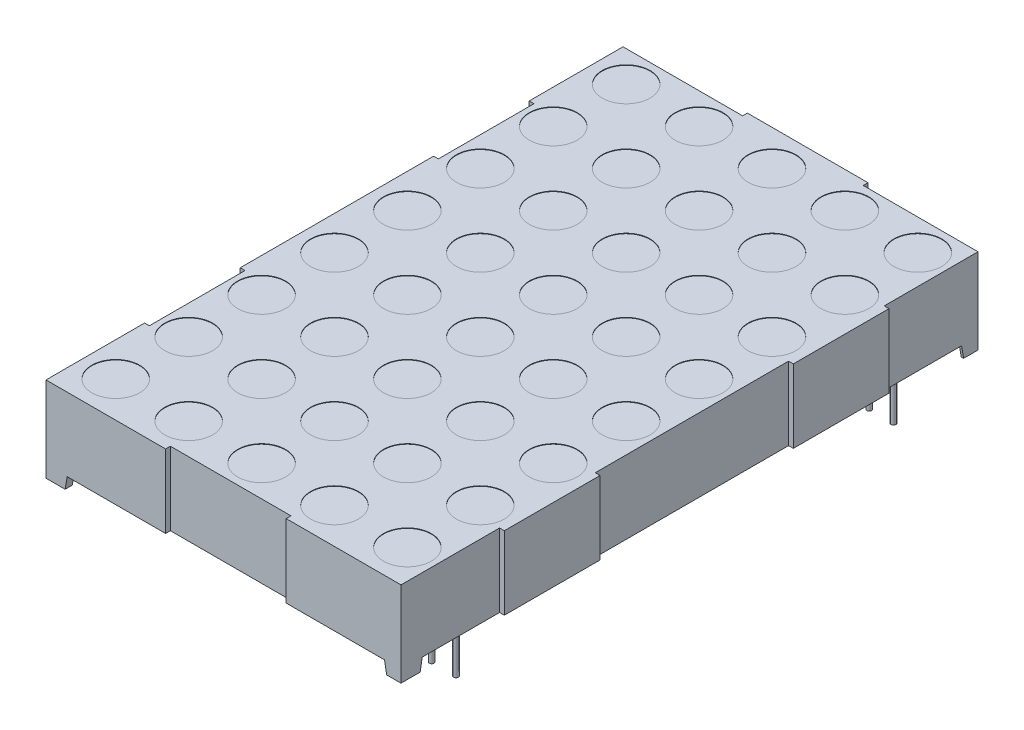
from build123d import *
from build123d.topology import SkipClean

# Parameters (mm, degrees)
EXTRUDE1_DEPTH     = 18.8
CUT_EXTRUDE1_DEPTH = 61.8
SKETCH2_R          = 2.5
CUT_EXTRUDE2_DEPTH = 0.05
SKETCH4_R          = 0.25
EXTRUDE2_DEPTH     = 1.25
SKETCH4_3_R        = 0.25
EXTRUDE3_DEPTH     = 4
SKETCH4_4_W        = 1.470408726
SKETCH4_4_H        = 1.470408726
CUT_EXTRUDE3_DEPTH = 1.25
SKETCH2_4_W        = 0.5
SKETCH2_4_H        = 10
SKETCH2_4_H_2      = 10.3
SKETCH2_4_H_3      = 20.2
SKETCH2_4_W_2      = 12.5
SKETCH2_4_H_4      = 0.5
SKETCH2_4_W_3      = 12
SKETCH2_4_W_4      = 12.6
CUT_EXTRUDE5_DEPTH = 13.9
SKETCH5_W          = 0.025316456
SKETCH5_H          = 0.026582279
CUT_EXTRUDE6_DEPTH = 0.01


with BuildPart() as part:
    # Sketch1 → Extrude1 (new body, symmetric)
    with BuildSketch(Plane(origin=(0, 0, 0), x_dir=(0, 0, -1), z_dir=(1, 0, 0))):
        Polygon((30.4, 4.45), (-30.4, 4.45), (21.860674157, -3.2), (28.179591274, -3.2), (28.347010236, -4.149480117), (30.4, -4.45), align=None)
        Polygon((21.860674157, -3.2), (-30.4, 4.45), (-30.4, -4.45), (-28.4, -4.45), (-28.179591274, -3.2), align=None)
        Polygon((30.4, -4.45), (28.347010236, -4.149480117), (28.4, -4.45), align=None)
    extrude(amount=EXTRUDE1_DEPTH, both=True)

    # Sketch3 → Cut-Extrude1 (cut, through all)
    with BuildSketch(Plane.XY.offset(30.4)):
        Polygon((-16.579591274, -3.2), (-16.8, -4.45), (16.8, -4.45), (16.579591274, -3.2), align=None)
    extrude(amount=-CUT_EXTRUDE1_DEPTH, mode=Mode.SUBTRACT)

    # Sketch2 → Cut-Extrude2 (cut)
    with BuildSketch(Plane(origin=(0, 4.45, 0), x_dir=(-1, 0, 0), z_dir=(0, 1, 0))):
        with Locations(Location((15.24, -19.05, 0), (0, 0, 90))):  # turned: the seam where the file's is
            Circle(SKETCH2_R)
        with Locations(Location((7.62, -19.05, 0), (0, 0, 90))):  # turned: the seam where the file's is
            Circle(SKETCH2_R)
        with Locations(Location((0, -19.05, 0), (0, 0, 90))):  # turned: the seam where the file's is
            Circle(SKETCH2_R)
        with Locations(Location((-7.62, -19.05, 0), (0, 0, 90))):  # turned: the seam where the file's is
            Circle(SKETCH2_R)
        with Locations(Location((-15.24, -19.05, 0), (0, 0, 90))):  # turned: the seam where the file's is
            Circle(SKETCH2_R)
        with Locations(Location((-15.24, -11.43, 0), (0, 0, 90))):  # turned: the seam where the file's is
            Circle(SKETCH2_R)
        with Locations(Location((-7.62, -11.43, 0), (0, 0, 90))):  # turned: the seam where the file's is
            Circle(SKETCH2_R)
        with Locations(Location((0, -11.43, 0), (0, 0, 90))):  # turned: the seam where the file's is
            Circle(SKETCH2_R)
        with Locations(Location((7.62, -11.43, 0), (0, 0, 90))):  # turned: the seam where the file's is
            Circle(SKETCH2_R)
        with Locations(Location((15.24, -11.43, 0), (0, 0, 90))):  # turned: the seam where the file's is
            Circle(SKETCH2_R)
        with Locations(Location((15.24, -3.81, 0), (0, 0, 90))):  # turned: the seam where the file's is
            Circle(SKETCH2_R)
        with Locations(Location((7.62, -3.81, 0), (0, 0, 90))):  # turned: the seam where the file's is
            Circle(SKETCH2_R)
        with Locations(Location((0, -3.81, 0), (0, 0, 90))):  # turned: the seam where the file's is
            Circle(SKETCH2_R)
        with Locations(Location((-7.62, -3.81, 0), (0, 0, 90))):  # turned: the seam where the file's is
            Circle(SKETCH2_R)
        with Locations(Location((-15.24, -3.81, 0), (0, 0, 90))):  # turned: the seam where the file's is
            Circle(SKETCH2_R)
        with Locations(Location((-15.24, 3.81, 0), (0, 0, 90))):  # turned: the seam where the file's is
            Circle(SKETCH2_R)
        with Locations(Location((-7.62, 3.81, 0), (0, 0, 90))):  # turned: the seam where the file's is
            Circle(SKETCH2_R)
        with Locations(Location((0, 3.81, 0), (0, 0, 90))):  # turned: the seam where the file's is
            Circle(SKETCH2_R)
        with Locations(Location((7.62, 3.81, 0), (0, 0, 90))):  # turned: the seam where the file's is
            Circle(SKETCH2_R)
        with Locations(Location((15.24, 3.81, 0), (0, 0, 90))):  # turned: the seam where the file's is
            Circle(SKETCH2_R)
        with Locations(Location((15.24, 11.43, 0), (0, 0, 90))):  # turned: the seam where the file's is
            Circle(SKETCH2_R)
        with Locations(Location((7.62, 11.43, 0), (0, 0, 90))):  # turned: the seam where the file's is
            Circle(SKETCH2_R)
        with Locations(Location((0, 11.43, 0), (0, 0, 90))):  # turned: the seam where the file's is
            Circle(SKETCH2_R)
        with Locations(Location((-7.62, 11.43, 0), (0, 0, 90))):  # turned: the seam where the file's is
            Circle(SKETCH2_R)
        with Locations(Location((-15.24, 11.43, 0), (0, 0, 90))):  # turned: the seam where the file's is
            Circle(SKETCH2_R)
        with Locations(Location((-15.24, 19.05, 0), (0, 0, 90))):  # turned: the seam where the file's is
            Circle(SKETCH2_R)
        with Locations(Location((-7.62, 19.05, 0), (0, 0, 90))):  # turned: the seam where the file's is
            Circle(SKETCH2_R)
        with Locations(Location((0, 19.05, 0), (0, 0, 90))):  # turned: the seam where the file's is
            Circle(SKETCH2_R)
        with Locations(Location((7.62, 19.05, 0), (0, 0, 90))):  # turned: the seam where the file's is
            Circle(SKETCH2_R)
        with Locations(Location((15.24, 19.05, 0), (0, 0, 90))):  # turned: the seam where the file's is
            Circle(SKETCH2_R)
        with Locations(Location((15.24, 26.67, 0), (0, 0, 90))):  # turned: the seam where the file's is
            Circle(SKETCH2_R)
        with Locations(Location((7.62, 26.67, 0), (0, 0, 90))):  # turned: the seam where the file's is
            Circle(SKETCH2_R)
        with Locations(Location((0, 26.67, 0), (0, 0, 90))):  # turned: the seam where the file's is
            Circle(SKETCH2_R)
        with Locations(Location((-7.62, 26.67, 0), (0, 0, 90))):  # turned: the seam where the file's is
            Circle(SKETCH2_R)
        with Locations(Location((-15.24, 26.67, 0), (0, 0, 90))):  # turned: the seam where the file's is
            Circle(SKETCH2_R)
        with Locations(Location((15.24, -26.67, 0), (0, 0, 90))):  # turned: the seam where the file's is
            Circle(SKETCH2_R)
        with Locations(Location((7.62, -26.67, 0), (0, 0, 90))):  # turned: the seam where the file's is
            Circle(SKETCH2_R)
        with Locations(Location((0, -26.67, 0), (0, 0, 90))):  # turned: the seam where the file's is
            Circle(SKETCH2_R)
        with Locations(Location((-7.62, -26.67, 0), (0, 0, 90))):  # turned: the seam where the file's is
            Circle(SKETCH2_R)
        with Locations(Location((-15.24, -26.67, 0), (0, 0, 90))):  # turned: the seam where the file's is
            Circle(SKETCH2_R)
    extrude(amount=-CUT_EXTRUDE2_DEPTH, mode=Mode.SUBTRACT)

    # Sketch4 → Extrude2 (add)
    with BuildSketch(Plane.XZ.offset(4.45)):
        with Locations((-6.35, 22.86)):
            Circle(SKETCH4_R)
        with Locations(Location((-3.81, 22.86, 0), (0, 0, 270))):  # turned: the seam where the file's is
            Circle(SKETCH4_R)
        with Locations(Location((-1.27, 22.86, 0), (0, 0, 270))):  # turned: the seam where the file's is
            Circle(SKETCH4_R)
        with Locations(Location((8.89, 22.86, 0), (0, 0, 270))):  # turned: the seam where the file's is
            Circle(SKETCH4_R)
        with Locations((1.27, 22.86)):
            Circle(SKETCH4_R)
        with Locations(Location((3.81, 22.86, 0), (0, 0, 270))):  # turned: the seam where the file's is
            Circle(SKETCH4_R)
        with Locations(Location((6.35, 22.86, 0), (0, 0, 270))):  # turned: the seam where the file's is
            Circle(SKETCH4_R)
        with Locations(Location((-1.27, -22.86, 0), (0, 0, 180))):  # turned: the seam where the file's is
            Circle(SKETCH4_R)
        with Locations(Location((16.51, -22.86, 0), (0, 0, 180))):  # turned: the seam where the file's is
            Circle(SKETCH4_R)
        with Locations(Location((13.97, -22.86, 0), (0, 0, 180))):  # turned: the seam where the file's is
            Circle(SKETCH4_R)
        with Locations(Location((-16.51, -22.86, 0), (0, 0, 180))):  # turned: the seam where the file's is
            Circle(SKETCH4_R)
        with Locations(Location((-13.97, -22.86, 0), (0, 0, 180))):  # turned: the seam where the file's is
            Circle(SKETCH4_R)
        with Locations(Location((-11.43, -22.86, 0), (0, 0, 180))):  # turned: the seam where the file's is
            Circle(SKETCH4_R)
        with Locations(Location((-8.89, -22.86, 0), (0, 0, 180))):  # turned: the seam where the file's is
            Circle(SKETCH4_R)
        with Locations((11.43, 22.86)):
            Circle(SKETCH4_R)
        with Locations((-8.89, 22.86)):
            Circle(SKETCH4_R)
        with Locations(Location((11.43, -22.86, 0), (0, 0, 180))):  # turned: the seam where the file's is
            Circle(SKETCH4_R)
        with Locations(Location((6.35, -22.86, 0), (0, 0, 180))):  # turned: the seam where the file's is
            Circle(SKETCH4_R)
        with Locations((-11.43, 22.86)):
            Circle(SKETCH4_R)
        with Locations((-13.97, 22.86)):
            Circle(SKETCH4_R)
        with Locations((-16.51, 22.86)):
            Circle(SKETCH4_R)
        with Locations((13.97, 22.86)):
            Circle(SKETCH4_R)
        with Locations((16.51, 22.86)):
            Circle(SKETCH4_R)
        with Locations(Location((3.81, -22.86, 0), (0, 0, 180))):  # turned: the seam where the file's is
            Circle(SKETCH4_R)
        with Locations(Location((1.27, -22.86, 0), (0, 0, 180))):  # turned: the seam where the file's is
            Circle(SKETCH4_R)
        with Locations(Location((8.89, -22.86, 0), (0, 0, 180))):  # turned: the seam where the file's is
            Circle(SKETCH4_R)
        with Locations(Location((-3.81, -22.86, 0), (0, 0, 180))):  # turned: the seam where the file's is
            Circle(SKETCH4_R)
        with Locations(Location((-6.35, -22.86, 0), (0, 0, 180))):  # turned: the seam where the file's is
            Circle(SKETCH4_R)
    extrude(amount=-EXTRUDE2_DEPTH)

    # Sketch4_3 → Extrude3 (add)
    with SkipClean():  # keep this step's faces unmerged: merging them makes the solid invalid here
        with BuildSketch(Plane.XZ.offset(4.45)):
            with Locations((-6.35, 22.86)):
                Circle(SKETCH4_3_R)
            with Locations((-3.81, 22.86)):
                Circle(SKETCH4_3_R)
            with Locations((-1.27, 22.86)):
                Circle(SKETCH4_3_R)
            with Locations((8.89, 22.86)):
                Circle(SKETCH4_3_R)
            with Locations((1.27, 22.86)):
                Circle(SKETCH4_3_R)
            with Locations((3.81, 22.86)):
                Circle(SKETCH4_3_R)
            with Locations(Location((6.35, 22.86, 0), (0, 0, 270))):  # turned: the seam where the file's is
                Circle(SKETCH4_3_R)
            with Locations(Location((-1.27, -22.86, 0), (0, 0, 180))):  # turned: the seam where the file's is
                Circle(SKETCH4_3_R)
            with Locations(Location((16.51, -22.86, 0), (0, 0, 180))):  # turned: the seam where the file's is
                Circle(SKETCH4_3_R)
            with Locations(Location((13.97, -22.86, 0), (0, 0, 180))):  # turned: the seam where the file's is
                Circle(SKETCH4_3_R)
            with Locations(Location((-16.51, -22.86, 0), (0, 0, 180))):  # turned: the seam where the file's is
                Circle(SKETCH4_3_R)
            with Locations(Location((-13.97, -22.86, 0), (0, 0, 180))):  # turned: the seam where the file's is
                Circle(SKETCH4_3_R)
            with Locations(Location((-11.43, -22.86, 0), (0, 0, 180))):  # turned: the seam where the file's is
                Circle(SKETCH4_3_R)
            with Locations(Location((-8.89, -22.86, 0), (0, 0, 180))):  # turned: the seam where the file's is
                Circle(SKETCH4_3_R)
            with Locations((11.43, 22.86)):
                Circle(SKETCH4_3_R)
            with Locations((-8.89, 22.86)):
                Circle(SKETCH4_3_R)
            with Locations(Location((11.43, -22.86, 0), (0, 0, 180))):  # turned: the seam where the file's is
                Circle(SKETCH4_3_R)
            with Locations(Location((6.35, -22.86, 0), (0, 0, 180))):  # turned: the seam where the file's is
                Circle(SKETCH4_3_R)
            with Locations((-11.43, 22.86)):
                Circle(SKETCH4_3_R)
            with Locations((-13.97, 22.86)):
                Circle(SKETCH4_3_R)
            with Locations((-16.51, 22.86)):
                Circle(SKETCH4_3_R)
            with Locations((13.97, 22.86)):
                Circle(SKETCH4_3_R)
            with Locations((16.51, 22.86)):
                Circle(SKETCH4_3_R)
            with Locations(Location((3.81, -22.86, 0), (0, 0, 180))):  # turned: the seam where the file's is
                Circle(SKETCH4_3_R)
            with Locations(Location((1.27, -22.86, 0), (0, 0, 180))):  # turned: the seam where the file's is
                Circle(SKETCH4_3_R)
            with Locations(Location((8.89, -22.86, 0), (0, 0, 180))):  # turned: the seam where the file's is
                Circle(SKETCH4_3_R)
            with Locations(Location((-3.81, -22.86, 0), (0, 0, 180))):  # turned: the seam where the file's is
                Circle(SKETCH4_3_R)
            with Locations(Location((-6.35, -22.86, 0), (0, 0, 180))):  # turned: the seam where the file's is
                Circle(SKETCH4_3_R)
        extrude(amount=EXTRUDE3_DEPTH)

    # Sketch4_4 → Cut-Extrude3 (cut)
    with SkipClean():  # keep this step's faces unmerged: merging them makes the solid invalid here
        with BuildSketch(Plane.XZ.offset(4.45)):
            with Locations((-17.314795637, 28.914795637)):
                Rectangle(SKETCH4_4_W, SKETCH4_4_H)
            with Locations((17.314795637, 28.914795637)):
                Rectangle(SKETCH4_4_W, SKETCH4_4_H)
            with Locations((17.314795637, -28.914795637)):
                Rectangle(SKETCH4_4_W, SKETCH4_4_H)
            with Locations((-17.314795637, -28.914795637)):
                Rectangle(SKETCH4_4_W, SKETCH4_4_H)
        extrude(amount=-CUT_EXTRUDE3_DEPTH, mode=Mode.SUBTRACT)

    # Sketch2_4 → Cut-Extrude5 (cut, through all)
    with SkipClean():  # keep this step's faces unmerged: merging them makes the solid invalid here
        with BuildSketch(Plane(origin=(0, 4.45, 0), x_dir=(-1, 0, 0), z_dir=(0, 1, 0))):
            with Locations((18.55, -15.1)):
                Rectangle(SKETCH2_4_W, SKETCH2_4_H)
            with Locations((18.55, 15.1)):
                Rectangle(SKETCH2_4_W, SKETCH2_4_H)
            with Locations((-18.55, 25.25)):
                Rectangle(SKETCH2_4_W, SKETCH2_4_H_2)
            with Locations((-18.55, 0)):
                Rectangle(SKETCH2_4_W, SKETCH2_4_H_3)
            Polygon((-18.8, -30.4), (-18.3, -30.4), (-18.3, -29.9), (-18.3, -20.1), (-18.8, -20.1), align=None)
            with Locations((12.55, -30.15)):
                Rectangle(SKETCH2_4_W_2, SKETCH2_4_H_4)
            with Locations((-12.3, -30.15)):
                Rectangle(SKETCH2_4_W_3, SKETCH2_4_H_4)
            with Locations((0, 30.15)):
                Rectangle(SKETCH2_4_W_4, SKETCH2_4_H_4)
        extrude(amount=-CUT_EXTRUDE5_DEPTH, mode=Mode.SUBTRACT)

    # Sketch5 → Cut-Extrude6 (cut)
    with SkipClean():  # keep this step's faces unmerged: merging them makes the solid invalid here
        with BuildSketch(Plane.XZ.offset(3.2)):
            Polygon((0.649619863, 18.964879029), (0.673077141, 19.039562573), (0.697820021, 19.039562573), (0.71423616, 18.989226339), (0.729762268, 19.039562573), (0.755494071, 19.039562573), (0.778733787, 18.964879029), (0.75355578, 18.964879029), (0.740561318, 19.016362415), (0.724145179, 18.964879029), (0.70264597, 18.964879029), (0.686328723, 19.016362415), (0.673512268, 18.964879029), align=None)
            Polygon((0.515442647, 18.964879029), (0.538899926, 19.039562573), (0.563642806, 19.039562573), (0.580058945, 18.989226339), (0.595585052, 19.039562573), (0.621316856, 19.039562573), (0.644556571, 18.964879029), (0.619378565, 18.964879029), (0.606384103, 19.016362415), (0.589967964, 18.964879029), (0.568468755, 18.964879029), (0.552151508, 19.016362415), (0.539335052, 18.964879029), align=None)
            Polygon((0.381265432, 18.964879029), (0.404722711, 19.039562573), (0.42946559, 19.039562573), (0.44588173, 18.989226339), (0.461407837, 19.039562573), (0.487139641, 19.039562573), (0.510379356, 18.964879029), (0.48520135, 18.964879029), (0.472206888, 19.016362415), (0.455790749, 18.964879029), (0.43429154, 18.964879029), (0.417974293, 19.016362415), (0.405157837, 18.964879029), align=None)
            with Locations((0.353417331, 19.026271433)):
                Rectangle(SKETCH5_W, SKETCH5_H)
            with BuildLine():
                add(Edge.make_bspline(
                    [(0.236961635, 19.008391687), (0.236998163, 19.009613801), (0.237069892, 19.012013625), (0.237679054, 19.015521591), (0.238674578, 19.018844874), (0.240038916, 19.02200759), (0.241852904, 19.024962956), (0.244007918, 19.027781523), (0.246619832, 19.030365485), (0.249556869, 19.032804246), (0.252854796, 19.034986641), (0.256457418, 19.036886779), (0.260327738, 19.038511498), (0.264481758, 19.039843187), (0.268927336, 19.040833955), (0.273645113, 19.041557272), (0.278638461, 19.04203078), (0.282062049, 19.042072721), (0.283816856, 19.042094218)],
                    knots=[0, 0, 0, 0, 0.907421153, 1.781872267, 2.635683434, 3.480115191, 4.332689235, 5.205575272, 6.109500117, 7.055808355, 8.037942167, 9.041423561, 10.07750834, 11.152467461, 12.277657752, 13.45734338, 14.696726425, 16, 16, 16, 16], degree=3))
                add(Edge.make_bspline(
                    [(0.283816856, 19.042094218), (0.285834841, 19.042066954), (0.289743027, 19.04201415), (0.295410595, 19.041628777), (0.300674061, 19.040940827), (0.305571809, 19.039984247), (0.310176109, 19.038780962), (0.314609454, 19.037490318), (0.318890746, 19.036025737), (0.321663838, 19.034925601), (0.323037584, 19.034380611)],
                    knots=[0, 0, 0, 0, 1.203182053, 2.33017619, 3.384818652, 4.366208123, 5.30340534, 6.221361684, 7.118890722, 8, 8, 8, 8], degree=3))
                Line((0.323037584, 19.034380611), (0.323037584, 19.010448649))
                Line((0.323037584, 19.010448649), (0.320189483, 19.010448649))
                add(Edge.make_bspline(
                    [(0.320189483, 19.010448649), (0.31882392, 19.011529612), (0.31610081, 19.013685191), (0.311673852, 19.016453545), (0.30701484, 19.018826555), (0.302176446, 19.020809178), (0.297275078, 19.022384792), (0.29240601, 19.023511698), (0.287637028, 19.024251062), (0.284478706, 19.024332623), (0.282926825, 19.024372699)],
                    knots=[0, 0, 0, 0, 1.030738938, 2.055426519, 3.085610749, 4.123842265, 5.148648843, 6.130724483, 7.081507926, 8, 8, 8, 8], degree=3))
                add(Edge.make_bspline(
                    [(0.282926825, 19.024372699), (0.282498078, 19.024371399), (0.281580166, 19.024368614), (0.280111018, 19.024247299), (0.278454674, 19.024119455), (0.276673936, 19.023923341), (0.274886731, 19.023692196), (0.273226484, 19.023345729), (0.271725722, 19.022976578), (0.270819053, 19.022609312), (0.270387268, 19.022434408)],
                    knots=[0, 0, 0, 0, 0.806537132, 1.726733348, 2.77251655, 3.932999672, 5.098049949, 6.161349231, 7.124375527, 8, 8, 8, 8], degree=3))
                add(Edge.make_bspline(
                    [(0.270387268, 19.022434408), (0.269907781, 19.022206173), (0.268965489, 19.021757641), (0.267662958, 19.020943731), (0.266492473, 19.020048986), (0.265431771, 19.019087253), (0.264569375, 19.017924265), (0.263948214, 19.016524994), (0.263603644, 19.014875701), (0.263564572, 19.013700539), (0.263543913, 19.013079187)],
                    knots=[0, 0, 0, 0, 1.02474257, 2.013837243, 2.958431669, 3.867978675, 4.769292696, 5.732237074, 6.800947934, 8, 8, 8, 8], degree=3))
                add(Edge.make_bspline(
                    [(0.263543913, 19.013079187), (0.263575375, 19.012533321), (0.263637237, 19.011459987), (0.264218743, 19.009931557), (0.26510279, 19.008511421), (0.266382205, 19.007246085), (0.267995883, 19.006119973), (0.269926871, 19.00510921), (0.272200721, 19.004273452), (0.273837934, 19.00383558), (0.274698977, 19.003605294)],
                    knots=[0, 0, 0, 0, 0.825427492, 1.623033598, 2.45033906, 3.348940377, 4.33183287, 5.428402891, 6.647546779, 8, 8, 8, 8], degree=3))
                add(Edge.make_bspline(
                    [(0.274698977, 19.003605294), (0.276668217, 19.00316009), (0.280703429, 19.002247812), (0.286843242, 19.001060358), (0.292981945, 18.999834487), (0.296938201, 18.998620172), (0.29886828, 18.998027763)],
                    knots=[0, 0, 0, 0, 0.976118991, 2.000185432, 3.024380873, 4, 4, 4, 4], degree=3))
                add(Edge.make_bspline(
                    [(0.29886828, 18.998027763), (0.299906433, 18.99767404), (0.301927295, 18.996985485), (0.304826487, 18.995832837), (0.307469734, 18.994527703), (0.309927274, 18.993205665), (0.312119938, 18.991725607), (0.314114571, 18.990192848), (0.315867232, 18.988540043), (0.31739367, 18.986790551), (0.318736536, 18.984954189), (0.319889945, 18.983007048), (0.320850968, 18.980940598), (0.32167436, 18.978785201), (0.322285587, 18.976510666), (0.322708023, 18.974134249), (0.323006086, 18.971650762), (0.323026942, 18.969956427), (0.323037584, 18.969091845)],
                    knots=[0, 0, 0, 0, 1.287376879, 2.505999703, 3.65855109, 4.746193839, 5.778582289, 6.760029101, 7.696159662, 8.601061861, 9.48181646, 10.363080883, 11.252765705, 12.153987336, 13.068239035, 14.012364187, 14.985753787, 16, 16, 16, 16], degree=3))
                add(Edge.make_bspline(
                    [(0.323037584, 18.969091845), (0.323000284, 18.967935699), (0.322926877, 18.965660424), (0.322325427, 18.962331401), (0.321298917, 18.959182583), (0.319912557, 18.956179427), (0.318085064, 18.953365163), (0.315892941, 18.950687677), (0.313282631, 18.948195181), (0.310297304, 18.945896544), (0.307010457, 18.943817739), (0.303476451, 18.941981031), (0.2996976, 18.940474584), (0.295717715, 18.939193353), (0.291498322, 18.938240957), (0.287061352, 18.937521379), (0.28238749, 18.937108379), (0.279196078, 18.937057104), (0.277566856, 18.937030927)],
                    knots=[0, 0, 0, 0, 0.894901293, 1.761149761, 2.608783409, 3.453876344, 4.314933854, 5.200038827, 6.12799933, 7.103249695, 8.113098521, 9.136064399, 10.182719798, 11.259667356, 12.370545059, 13.528828137, 14.738461593, 16, 16, 16, 16], degree=3))
                add(Edge.make_bspline(
                    [(0.277566856, 18.937030927), (0.275898205, 18.93705332), (0.272563731, 18.937098068), (0.267581758, 18.937473037), (0.262624343, 18.938039538), (0.257752779, 18.938838993), (0.253070272, 18.939856648), (0.248653658, 18.940942607), (0.244574688, 18.942182996), (0.242000963, 18.943137042), (0.240759103, 18.943597383)],
                    knots=[0, 0, 0, 0, 1.065379838, 2.128953261, 3.188461447, 4.250817766, 5.279613205, 6.247547721, 7.154416075, 8, 8, 8, 8], degree=3))
                Line((0.240759103, 18.943597383), (0.240759103, 18.966144851))
                Line((0.240759103, 18.966144851), (0.243587426, 18.966144851))
                add(Edge.make_bspline(
                    [(0.243587426, 18.966144851), (0.244660385, 18.965344648), (0.246854616, 18.96370821), (0.250513369, 18.961622233), (0.254477429, 18.959672719), (0.25874233, 18.957950925), (0.263214871, 18.956530325), (0.267792417, 18.955501281), (0.272419482, 18.954862157), (0.275521073, 18.954789025), (0.277072394, 18.954752446)],
                    knots=[0, 0, 0, 0, 0.89224925, 1.824673196, 2.804309561, 3.838364047, 4.890042674, 5.931526337, 6.965412421, 8, 8, 8, 8], degree=3))
                add(Edge.make_bspline(
                    [(0.277072394, 18.954752446), (0.278167694, 18.954776656), (0.280357439, 18.954825057), (0.283631847, 18.955174311), (0.286866639, 18.955846052), (0.288909537, 18.956660388), (0.289928407, 18.957066529)],
                    knots=[0, 0, 0, 0, 0.998993879, 1.997209027, 3.00113285, 4, 4, 4, 4], degree=3))
                add(Edge.make_bspline(
                    [(0.289928407, 18.957066529), (0.290361886, 18.957268011), (0.291228556, 18.957670842), (0.292435559, 18.958443168), (0.293538863, 18.959372886), (0.294539868, 18.96042528), (0.295387924, 18.961594615), (0.296025584, 18.962864374), (0.296386403, 18.964226353), (0.29643224, 18.965160521), (0.296455306, 18.965630611)],
                    knots=[0, 0, 0, 0, 1.005454979, 2.010239304, 3.005296729, 4.036100111, 5.060531193, 6.034954812, 7.011155677, 8, 8, 8, 8], degree=3))
                add(Edge.make_bspline(
                    [(0.296455306, 18.965630611), (0.296420511, 18.966268542), (0.296354023, 18.96748757), (0.295754025, 18.969201266), (0.294756356, 18.970664378), (0.293603257, 18.971657371), (0.292486278, 18.972356131), (0.291445761, 18.972861371), (0.29024631, 18.973374793), (0.288868861, 18.973863991), (0.287333726, 18.974358037), (0.285624803, 18.974832707), (0.283742196, 18.975282266), (0.282426305, 18.975568418), (0.281740116, 18.975717636)],
                    knots=[0, 0, 0, 0, 1.174343879, 2.244064321, 3.303704314, 4.407076671, 5.02483983, 5.732197225, 6.53898402, 7.431906431, 8.428480183, 9.514816237, 10.704066255, 12, 12, 12, 12], degree=3))
                add(Edge.make_bspline(
                    [(0.281740116, 18.975717636), (0.279907491, 18.976094356), (0.276306788, 18.976834528), (0.270901713, 18.977928825), (0.265408659, 18.979241342), (0.261738109, 18.980370554), (0.259825559, 18.980958934)],
                    knots=[0, 0, 0, 0, 0.995788186, 1.956503735, 2.935230479, 4, 4, 4, 4], degree=3))
                add(Edge.make_bspline(
                    [(0.259825559, 18.980958934), (0.258879002, 18.981278175), (0.257027385, 18.981902663), (0.254386787, 18.982988981), (0.251939614, 18.984162838), (0.249672979, 18.985404807), (0.247597614, 18.986747241), (0.245711324, 18.988172574), (0.244013367, 18.989677357), (0.242524619, 18.991293077), (0.241195861, 18.993003425), (0.240083517, 18.994854038), (0.239087932, 18.996797567), (0.238334777, 18.99889101), (0.237710268, 19.001089538), (0.237288525, 19.003421472), (0.236994162, 19.00586569), (0.236972598, 19.007540289), (0.236961635, 19.008391687)],
                    knots=[0, 0, 0, 0, 1.237326419, 2.420410185, 3.534642089, 4.598489486, 5.620241961, 6.59385002, 7.525152549, 8.426792174, 9.312230456, 10.203151844, 11.098070343, 12.012931196, 12.954244379, 13.926618287, 14.945853925, 16, 16, 16, 16], degree=3))
            make_face()
            with BuildLine():
                Line((0.144556571, 19.039562573), (0.168607204, 19.039562573))
                Line((0.168607204, 19.039562573), (0.168607204, 19.031730294))
                add(Edge.make_bspline(
                    [(0.168607204, 19.031730294), (0.169700398, 19.032539089), (0.17180806, 19.034098434), (0.174982619, 19.036175496), (0.178000919, 19.037959918), (0.180931271, 19.039483035), (0.183937548, 19.040695206), (0.187175682, 19.041513586), (0.190677278, 19.04201631), (0.193104348, 19.042067672), (0.194358787, 19.042094218)],
                    knots=[0, 0, 0, 0, 1.150945962, 2.219006967, 3.209666795, 4.118194914, 5.012574058, 5.946577101, 6.93868214, 8, 8, 8, 8], degree=3))
                add(Edge.make_bspline(
                    [(0.194358787, 19.042094218), (0.195375062, 19.042071271), (0.197354043, 19.042026584), (0.200232342, 19.041684864), (0.202934308, 19.041136455), (0.205463145, 19.040368048), (0.207812845, 19.039365017), (0.209956525, 19.038093382), (0.211959102, 19.036660669), (0.213741049, 19.034954303), (0.215356595, 19.033056385), (0.216739166, 19.030923976), (0.217916871, 19.028591036), (0.218857971, 19.026039186), (0.21961306, 19.023280882), (0.220136992, 19.020301634), (0.220457585, 19.017114507), (0.220489524, 19.014919376), (0.220505939, 19.013791212)],
                    knots=[0, 0, 0, 0, 1.108959949, 2.159465255, 3.158589008, 4.114545495, 5.039534357, 5.93921201, 6.830099133, 7.720870013, 8.624681761, 9.544731627, 10.487599671, 11.471264588, 12.508152322, 13.604835107, 14.769030043, 16, 16, 16, 16], degree=3))
                Line((0.220505939, 19.013791212), (0.220505939, 18.964879029))
                Line((0.220505939, 18.964879029), (0.196455306, 18.964879029))
                Line((0.196455306, 18.964879029), (0.196455306, 19.002458143))
                add(Edge.make_bspline(
                    [(0.196455306, 19.002458143), (0.19645367, 19.003374613), (0.196450539, 19.005128829), (0.196368201, 19.007634636), (0.1962473, 19.009902808), (0.196108595, 19.011944837), (0.195855579, 19.013791588), (0.19547787, 19.015457749), (0.195007044, 19.01697735), (0.194542725, 19.017884052), (0.19431923, 19.018320484)],
                    knots=[0, 0, 0, 0, 1.361401701, 2.605856924, 3.723918663, 4.735739235, 5.645738665, 6.489217889, 7.27279937, 8, 8, 8, 8], degree=3))
                add(Edge.make_bspline(
                    [(0.19431923, 19.018320484), (0.194089221, 19.01871919), (0.193637044, 19.019503011), (0.19271678, 19.020509322), (0.191637937, 19.021353073), (0.190360734, 19.022011174), (0.188871167, 19.022501677), (0.187150308, 19.022882248), (0.185158567, 19.023054126), (0.183751099, 19.023088616), (0.183005939, 19.023106877)],
                    knots=[0, 0, 0, 0, 0.849004071, 1.669068917, 2.503060811, 3.370079215, 4.310762265, 5.396376419, 6.621555549, 8, 8, 8, 8], degree=3))
                add(Edge.make_bspline(
                    [(0.183005939, 19.023106877), (0.182464996, 19.023087038), (0.18135358, 19.023046276), (0.179636127, 19.022854735), (0.177846867, 19.022455576), (0.175328198, 19.021810632), (0.172162988, 19.020616777), (0.169803454, 19.019263631), (0.168607204, 19.018577605)],
                    knots=[0, 0, 0, 0, 0.638062719, 1.310959128, 2.033463623, 2.796942592, 4.376095945, 6, 6, 6, 6], degree=3))
                Line((0.168607204, 19.018577605), (0.168607204, 18.964879029))
                Line((0.168607204, 18.964879029), (0.144556571, 18.964879029))
                Line((0.144556571, 18.964879029), (0.144556571, 19.039562573))
            make_face()
            with BuildLine():
                Line((0.047088217, 19.039562573), (0.07113885, 19.039562573))
                Line((0.07113885, 19.039562573), (0.07113885, 19.001983459))
                add(Edge.make_bspline(
                    [(0.07113885, 19.001983459), (0.071163856, 19.00045347), (0.071213828, 18.997395978), (0.071490379, 18.993632884), (0.071874866, 18.990791344), (0.072242405, 18.988959756), (0.072674277, 18.987411639), (0.073086538, 18.986525878), (0.073274926, 18.986121117)],
                    knots=[0, 0, 0, 0, 1.709111167, 3.415443484, 4.21113913, 4.910175115, 5.501990373, 6, 6, 6, 6], degree=3))
                add(Edge.make_bspline(
                    [(0.073274926, 18.986121117), (0.073519387, 18.985723054), (0.073998687, 18.984942596), (0.074936037, 18.983929719), (0.076029821, 18.983100351), (0.077300997, 18.982420884), (0.078789106, 18.981941696), (0.080513023, 18.981588942), (0.082493208, 18.981378388), (0.083902037, 18.981349835), (0.084647552, 18.981334725)],
                    knots=[0, 0, 0, 0, 0.860202684, 1.686548532, 2.528236983, 3.382486038, 4.33249885, 5.401154041, 6.624757403, 8, 8, 8, 8], degree=3))
                add(Edge.make_bspline(
                    [(0.084647552, 18.981334725), (0.085778442, 18.981394825), (0.088086137, 18.981517467), (0.090961447, 18.982184133), (0.093278785, 18.983044097), (0.095136502, 18.983794533), (0.097044224, 18.984768633), (0.098323766, 18.985490075), (0.098986951, 18.985863997)],
                    knots=[0, 0, 0, 0, 1.33818541, 2.730705359, 3.468371228, 4.262126284, 5.099261778, 6, 6, 6, 6], degree=3))
                Line((0.098986951, 18.985863997), (0.098986951, 19.039562573))
                Line((0.098986951, 19.039562573), (0.123037584, 19.039562573))
                Line((0.123037584, 19.039562573), (0.123037584, 18.964879029))
                Line((0.123037584, 18.964879029), (0.098986951, 18.964879029))
                Line((0.098986951, 18.964879029), (0.098986951, 18.972711307))
                add(Edge.make_bspline(
                    [(0.098986951, 18.972711307), (0.097929545, 18.971905155), (0.09587124, 18.970335933), (0.092692002, 18.968295513), (0.089608104, 18.966496744), (0.086555094, 18.964983927), (0.08344014, 18.963777152), (0.080177381, 18.962966163), (0.076760975, 18.96242236), (0.07442426, 18.962372667), (0.073235369, 18.962347383)],
                    knots=[0, 0, 0, 0, 1.126119141, 2.192057864, 3.198061997, 4.149848529, 5.076251285, 6.021887753, 6.99356175, 8, 8, 8, 8], degree=3))
                add(Edge.make_bspline(
                    [(0.073235369, 18.962347383), (0.072239104, 18.962372783), (0.070294217, 18.962422369), (0.067459368, 18.962731921), (0.064788262, 18.963283144), (0.062294877, 18.964079001), (0.059959191, 18.96507036), (0.057785519, 18.966274339), (0.05579967, 18.96773762), (0.053971518, 18.969397559), (0.052332418, 18.971288857), (0.050935508, 18.973418235), (0.049731146, 18.975755155), (0.048781881, 18.978317792), (0.047990557, 18.981084064), (0.047485793, 18.984082694), (0.047128141, 18.98729258), (0.047101791, 18.98950873), (0.047088217, 18.990650389)],
                    knots=[0, 0, 0, 0, 1.08828964, 2.12453497, 3.110382522, 4.062402335, 4.978696626, 5.878225494, 6.769849763, 7.667011675, 8.57076823, 9.495541561, 10.442454184, 11.436213583, 12.475881554, 13.580560132, 14.753614518, 16, 16, 16, 16], degree=3))
                Line((0.047088217, 18.990650389), (0.047088217, 19.039562573))
            make_face()
            Polygon((-0.047848492, 19.039562573), (0.024303407, 19.039562573), (0.024303407, 18.939562573), (-0.001013049, 18.939562573), (-0.001013049, 19.020575231), (-0.047848492, 19.020575231), align=None)
            Polygon((-0.135190264, 19.039562573), (-0.063038365, 19.039562573), (-0.063038365, 18.939562573), (-0.135190264, 18.939562573), (-0.135190264, 18.958549915), (-0.088354821, 18.958549915), (-0.088354821, 18.976271434), (-0.131392796, 18.976271434), (-0.131392796, 18.995258775), (-0.088354821, 18.995258775), (-0.088354821, 19.020575231), (-0.135190264, 19.020575231), align=None)
            with BuildLine():
                add(Edge.make_bspline(
                    [(-0.25164596, 18.989661465), (-0.251626645, 18.990809154), (-0.251588393, 18.99308204), (-0.251293201, 18.996446847), (-0.250767176, 18.999712522), (-0.250087995, 19.002896771), (-0.249165489, 19.005975699), (-0.248083775, 19.008983276), (-0.246774129, 19.011888769), (-0.245269277, 19.014690204), (-0.243619805, 19.017362306), (-0.241845055, 19.019882515), (-0.239999276, 19.022265733), (-0.238009964, 19.024460627), (-0.235930782, 19.026502646), (-0.233755254, 19.028393461), (-0.231450189, 19.030096891), (-0.229843026, 19.031119776), (-0.229039156, 19.031631402)],
                    knots=[0, 0, 0, 0, 1.105570398, 2.18947457, 3.250358341, 4.290584537, 5.323553275, 6.344225964, 7.367641686, 8.3905646, 9.405808457, 10.390761353, 11.358902336, 12.307789878, 13.241960776, 14.165076779, 15.082208636, 16, 16, 16, 16], degree=3))
                add(Edge.make_bspline(
                    [(-0.229039156, 19.031631402), (-0.227799969, 19.032343723), (-0.225315272, 19.033772), (-0.221330814, 19.035437839), (-0.217209205, 19.036852062), (-0.212850024, 19.037865503), (-0.208211303, 19.038635338), (-0.203206492, 19.039183509), (-0.197799586, 19.039489012), (-0.194064593, 19.039537494), (-0.192132511, 19.039562573)],
                    knots=[0, 0, 0, 0, 0.896321744, 1.797216976, 2.705381885, 3.628777036, 4.602292017, 5.655629376, 6.787275635, 8, 8, 8, 8], degree=3))
                Line((-0.192132511, 19.039562573), (-0.156709251, 19.039562573))
                Line((-0.156709251, 19.039562573), (-0.156709251, 18.939562573))
                Line((-0.156709251, 18.939562573), (-0.193141213, 18.939562573))
                add(Edge.make_bspline(
                    [(-0.193141213, 18.939562573), (-0.195119909, 18.939579383), (-0.198936569, 18.939611807), (-0.204453886, 18.940026735), (-0.209556224, 18.940632498), (-0.214245804, 18.941526684), (-0.218548253, 18.942641265), (-0.222465545, 18.944029796), (-0.226081778, 18.945522413), (-0.228260313, 18.946796967), (-0.229316055, 18.94741463)],
                    knots=[0, 0, 0, 0, 1.267083275, 2.444046388, 3.541868212, 4.55639609, 5.499737919, 6.385160515, 7.217431253, 8, 8, 8, 8], degree=3))
                add(Edge.make_bspline(
                    [(-0.229316055, 18.94741463), (-0.230167008, 18.947951171), (-0.231859133, 18.949018084), (-0.234260348, 18.950799936), (-0.236489775, 18.952756013), (-0.238618278, 18.954807832), (-0.240598095, 18.957010719), (-0.242441295, 18.959349426), (-0.244145112, 18.96182752), (-0.245703076, 18.964436989), (-0.247123891, 18.967167041), (-0.248313197, 18.9700401), (-0.249362546, 18.97301863), (-0.250168082, 18.976127592), (-0.250865996, 18.979335429), (-0.251300731, 18.982676773), (-0.251587341, 18.986129261), (-0.251626256, 18.988474151), (-0.25164596, 18.989661465)],
                    knots=[0, 0, 0, 0, 0.964065863, 1.917049184, 2.86229036, 3.805247319, 4.749389377, 5.698846072, 6.657678277, 7.629829384, 8.610569287, 9.604676042, 10.607940105, 11.6349849, 12.681042988, 13.752616828, 14.862056989, 16, 16, 16, 16], degree=3))
            make_face()
            with BuildLine():
                add(Edge.make_bspline(
                    [(-0.225063682, 18.989503237), (-0.225020379, 18.987924807), (-0.224936767, 18.984877008), (-0.224231372, 18.980481364), (-0.223092122, 18.976438414), (-0.22175443, 18.973325997), (-0.220417038, 18.97105268), (-0.219289514, 18.96945441), (-0.218039848, 18.96794021), (-0.216649239, 18.96653137), (-0.215114055, 18.965224334), (-0.213452796, 18.963995423), (-0.211652755, 18.962866778), (-0.210379724, 18.962206772), (-0.209735359, 18.961872699)],
                    knots=[0, 0, 0, 0, 1.694683197, 3.272273219, 4.767406206, 6.197615014, 6.895990032, 7.597410435, 8.296503208, 9.002591366, 9.720792421, 10.460154445, 11.220583224, 12, 12, 12, 12], degree=3))
                add(Edge.make_bspline(
                    [(-0.209735359, 18.961872699), (-0.209060424, 18.961566185), (-0.207722656, 18.960958652), (-0.20565238, 18.960224566), (-0.203559679, 18.959662239), (-0.201365451, 18.959189816), (-0.198888692, 18.95891268), (-0.1959662, 18.958700003), (-0.192509527, 18.958563076), (-0.190022931, 18.958554505), (-0.188691055, 18.958549915)],
                    knots=[0, 0, 0, 0, 0.826913061, 1.638999358, 2.447478739, 3.243919028, 4.140906711, 5.225381046, 6.513851968, 8, 8, 8, 8], degree=3))
                Line((-0.188691055, 18.958549915), (-0.182025707, 18.958549915))
                Line((-0.182025707, 18.958549915), (-0.182025707, 19.020575231))
                Line((-0.182025707, 19.020575231), (-0.188691055, 19.020575231))
                add(Edge.make_bspline(
                    [(-0.188691055, 19.020575231), (-0.189449246, 19.020570185), (-0.190912982, 19.020560445), (-0.193029435, 19.020521342), (-0.194994197, 19.020461025), (-0.196801547, 19.020389183), (-0.198457684, 19.020274279), (-0.199945518, 19.020105683), (-0.201287868, 19.019961295), (-0.202855503, 19.019694176), (-0.204708651, 19.019277721), (-0.206869917, 19.018599629), (-0.20901045, 19.01774921), (-0.210399023, 19.017064246), (-0.211100074, 19.016718427)],
                    knots=[0, 0, 0, 0, 1.186775798, 2.291144404, 3.313233901, 4.263515562, 5.122260739, 5.910868134, 6.60717912, 7.234883681, 8.398964994, 9.577230746, 10.776813768, 12, 12, 12, 12], degree=3))
                add(Edge.make_bspline(
                    [(-0.211100074, 19.016718427), (-0.211683788, 19.016374951), (-0.212831725, 19.015699467), (-0.214475869, 19.014593604), (-0.215962609, 19.013358605), (-0.217368671, 19.012075507), (-0.218621537, 19.010685053), (-0.21979483, 19.009234573), (-0.220805086, 19.00767218), (-0.222050081, 19.005478651), (-0.223269813, 19.002445281), (-0.224310573, 18.998478737), (-0.224947088, 18.994118728), (-0.225023822, 18.991081146), (-0.225063682, 18.989503237)],
                    knots=[0, 0, 0, 0, 0.755109416, 1.485004392, 2.205961541, 2.908125208, 3.605307969, 4.290649036, 4.985852759, 5.676964147, 7.100721462, 8.614478074, 10.241350405, 12, 12, 12, 12], degree=3))
            make_face(mode=Mode.SUBTRACT)
            with Locations((-0.28329153, 19.026271433)):
                Rectangle(SKETCH5_W, SKETCH5_H)
            with BuildLine():
                add(Edge.make_bspline(
                    [(-0.357935517, 19.042094218), (-0.356345412, 19.042072392), (-0.353224289, 19.042029551), (-0.348652845, 19.041552849), (-0.344288042, 19.040834382), (-0.340140424, 19.03981621), (-0.336233862, 19.038459868), (-0.332552809, 19.036841853), (-0.329163447, 19.034824047), (-0.327099717, 19.033247106), (-0.326072384, 19.032462098)],
                    knots=[0, 0, 0, 0, 1.123606455, 2.205459211, 3.245124445, 4.248821949, 5.220056174, 6.165006393, 7.086533249, 8, 8, 8, 8], degree=3))
                add(Edge.make_bspline(
                    [(-0.326072384, 19.032462098), (-0.325120637, 19.031607324), (-0.323220822, 19.029901081), (-0.320754889, 19.026929654), (-0.318631804, 19.02364661), (-0.316846251, 19.020044388), (-0.315415327, 19.016127659), (-0.314392193, 19.011882997), (-0.313772948, 19.007322216), (-0.313705783, 19.004174283), (-0.313671277, 19.002557035)],
                    knots=[0, 0, 0, 0, 0.916457077, 1.82937027, 2.759194969, 3.714948755, 4.706655623, 5.743329475, 6.840637961, 8, 8, 8, 8], degree=3))
                add(Edge.make_bspline(
                    [(-0.313671277, 19.002557035), (-0.313710037, 19.000853808), (-0.31378516, 18.997552728), (-0.31444892, 18.99278054), (-0.315518532, 18.98836286), (-0.31705609, 18.984310951), (-0.318986532, 18.98061776), (-0.321251025, 18.977245925), (-0.32387155, 18.974203001), (-0.325878689, 18.972457561), (-0.326883302, 18.971583934)],
                    knots=[0, 0, 0, 0, 1.171797512, 2.271099083, 3.308930235, 4.294129479, 5.24602549, 6.17106565, 7.084581485, 8, 8, 8, 8], degree=3))
                add(Edge.make_bspline(
                    [(-0.326883302, 18.971583934), (-0.327909215, 18.970815472), (-0.329973434, 18.969269268), (-0.333376278, 18.967366657), (-0.337003968, 18.965778463), (-0.340825704, 18.964501744), (-0.344800689, 18.963547127), (-0.348864244, 18.96285446), (-0.353008045, 18.962425779), (-0.355798426, 18.962373641), (-0.357203713, 18.962347383)],
                    knots=[0, 0, 0, 0, 0.952046378, 1.915591786, 2.889970712, 3.892742799, 4.906722985, 5.925995921, 6.955492795, 8, 8, 8, 8], degree=3))
                add(Edge.make_bspline(
                    [(-0.357203713, 18.962347383), (-0.358450518, 18.962363781), (-0.360902158, 18.962396024), (-0.364500998, 18.962726627), (-0.367958956, 18.963228564), (-0.371265875, 18.963967137), (-0.374432872, 18.964888754), (-0.377487011, 18.965920816), (-0.380446243, 18.967056047), (-0.382346888, 18.967940324), (-0.38329153, 18.96837982)],
                    knots=[0, 0, 0, 0, 1.107549047, 2.177816721, 3.208424937, 4.210433793, 5.185680559, 6.13785309, 7.074491882, 8, 8, 8, 8], degree=3))
                Line((-0.38329153, 18.96837982), (-0.38329153, 18.988929662))
                Line((-0.38329153, 18.988929662), (-0.379948966, 18.988929662))
                add(Edge.make_bspline(
                    [(-0.379948966, 18.988929662), (-0.379448389, 18.988513775), (-0.378363364, 18.987612323), (-0.376596532, 18.986165735), (-0.374426213, 18.984665445), (-0.372779183, 18.98377082), (-0.371899125, 18.983292794)],
                    knots=[0, 0, 0, 0, 0.792743043, 1.718305972, 2.780820752, 4, 4, 4, 4], degree=3))
                add(Edge.make_bspline(
                    [(-0.371899125, 18.983292794), (-0.370970189, 18.982854156), (-0.369064281, 18.981954196), (-0.366521073, 18.981076808), (-0.364317893, 18.980551439), (-0.362504233, 18.980285874), (-0.360569936, 18.980099015), (-0.35923479, 18.980079124), (-0.35854865, 18.980068902)],
                    knots=[0, 0, 0, 0, 1.332360773, 2.733622135, 3.480580446, 4.268165618, 5.10999921, 6, 6, 6, 6], degree=3))
                add(Edge.make_bspline(
                    [(-0.35854865, 18.980068902), (-0.357783011, 18.980088233), (-0.356299239, 18.980125695), (-0.354138871, 18.980405742), (-0.352114253, 18.980873835), (-0.350226215, 18.981551779), (-0.348472384, 18.982403545), (-0.346852361, 18.983444991), (-0.345358928, 18.984668262), (-0.344039987, 18.986109894), (-0.342847173, 18.987689634), (-0.341827996, 18.989423801), (-0.340915533, 18.991270386), (-0.340220596, 18.993274839), (-0.339660858, 18.995403614), (-0.339271928, 18.997666734), (-0.33902997, 19.000066244), (-0.339002053, 19.001712552), (-0.338987732, 19.002557035)],
                    knots=[0, 0, 0, 0, 1.087372478, 2.107277257, 3.088614887, 4.033572876, 4.950837204, 5.852283781, 6.763600506, 7.684681617, 8.621202104, 9.570420019, 10.537986648, 11.542161979, 12.577980734, 13.661919757, 14.800668594, 16, 16, 16, 16], degree=3))
                add(Edge.make_bspline(
                    [(-0.338987732, 19.002557035), (-0.339002507, 19.003421191), (-0.339031213, 19.005100204), (-0.339264727, 19.007541815), (-0.339680618, 19.009823246), (-0.340251866, 19.011948566), (-0.340976214, 19.013914584), (-0.341881331, 19.015711981), (-0.342917688, 19.017368788), (-0.344162246, 19.0188314), (-0.345526129, 19.020147721), (-0.347041021, 19.021283856), (-0.34870026, 19.022232001), (-0.350482441, 19.023036464), (-0.352415482, 19.023614862), (-0.354472018, 19.024051554), (-0.356661573, 19.024340111), (-0.358171927, 19.024361674), (-0.35894422, 19.024372699)],
                    knots=[0, 0, 0, 0, 1.230336593, 2.390482092, 3.487897344, 4.52859895, 5.520747884, 6.465347575, 7.38981449, 8.296085817, 9.192433006, 10.084246191, 10.984321635, 11.908883871, 12.862027947, 13.850751296, 14.901019963, 16, 16, 16, 16], degree=3))
                add(Edge.make_bspline(
                    [(-0.35894422, 19.024372699), (-0.359669985, 19.02436395), (-0.361084836, 19.024346893), (-0.363151836, 19.024137338), (-0.365109341, 19.023830567), (-0.366942483, 19.023390614), (-0.368645216, 19.022878063), (-0.37020155, 19.022305118), (-0.371614526, 19.021701992), (-0.372475816, 19.021234236), (-0.372888049, 19.021010358)],
                    knots=[0, 0, 0, 0, 1.201052708, 2.34140671, 3.435973211, 4.479046096, 5.459661032, 6.378175262, 7.223757638, 8, 8, 8, 8], degree=3))
                add(Edge.make_bspline(
                    [(-0.372888049, 19.021010358), (-0.373588254, 19.020580463), (-0.374942821, 19.019748821), (-0.376781549, 19.018347255), (-0.378426418, 19.016932995), (-0.37945093, 19.015976778), (-0.379948966, 19.01551194)],
                    knots=[0, 0, 0, 0, 1.098601379, 2.125273733, 3.088655601, 4, 4, 4, 4], degree=3))
                Line((-0.379948966, 19.01551194), (-0.38329153, 19.01551194))
                Line((-0.38329153, 19.01551194), (-0.38329153, 19.03622001))
                add(Edge.make_bspline(
                    [(-0.38329153, 19.03622001), (-0.38234614, 19.036657504), (-0.380455133, 19.037532597), (-0.377540554, 19.038686469), (-0.374552581, 19.03965463), (-0.371504208, 19.04055771), (-0.368332125, 19.041246072), (-0.365009095, 19.041739195), (-0.361527596, 19.042040107), (-0.359149207, 19.042075935), (-0.357935517, 19.042094218)],
                    knots=[0, 0, 0, 0, 0.952012952, 1.904254716, 2.862729541, 3.822037426, 4.808956931, 5.82647221, 6.890850784, 8, 8, 8, 8], degree=3))
            make_face()
            with BuildLine():
                add(Edge.make_bspline(
                    [(-0.475696593, 19.002260358), (-0.475671898, 19.003765264), (-0.47562376, 19.00669873), (-0.475084443, 19.010970521), (-0.474271663, 19.015006518), (-0.473099132, 19.018793727), (-0.471618739, 19.022351002), (-0.4697678, 19.025640794), (-0.467596795, 19.028694024), (-0.465105758, 19.031483908), (-0.462304556, 19.033982419), (-0.459230374, 19.036177672), (-0.455856547, 19.037991114), (-0.452242236, 19.039503204), (-0.448357584, 19.040672439), (-0.444203365, 19.041485157), (-0.439786231, 19.042020627), (-0.436747812, 19.042069279), (-0.435190264, 19.042094218)],
                    knots=[0, 0, 0, 0, 1.120167703, 2.183507516, 3.201345984, 4.182878364, 5.131270247, 6.065524964, 6.98789854, 7.91635504, 8.84481154, 9.778033504, 10.722808862, 11.691211189, 12.691525459, 13.738229926, 14.840575679, 16, 16, 16, 16], degree=3))
                add(Edge.make_bspline(
                    [(-0.435190264, 19.042094218), (-0.433632743, 19.042069196), (-0.430594377, 19.042020384), (-0.426176868, 19.041486053), (-0.422017773, 19.040668102), (-0.418128466, 19.039512001), (-0.41451972, 19.037985452), (-0.411149854, 19.036178404), (-0.408076088, 19.03398221), (-0.405274602, 19.031484019), (-0.402784284, 19.028693792), (-0.400610693, 19.02564161), (-0.398768279, 19.022345656), (-0.397250425, 19.01880261), (-0.396117101, 19.015001772), (-0.395293638, 19.010971331), (-0.39475743, 19.006698511), (-0.394708855, 19.00376519), (-0.394683935, 19.002260358)],
                    knots=[0, 0, 0, 0, 1.15937715, 2.261678054, 3.308339936, 4.313313916, 5.277148057, 6.221884977, 7.155068972, 8.083487698, 9.011906424, 9.934242473, 10.868459181, 11.818729666, 12.798784262, 13.81658132, 14.879877871, 16, 16, 16, 16], degree=3))
                add(Edge.make_bspline(
                    [(-0.394683935, 19.002260358), (-0.394709036, 19.000748925), (-0.39475808, 18.997795897), (-0.395293747, 18.99349715), (-0.396110709, 18.989436053), (-0.397276241, 18.985623503), (-0.398782518, 18.982061027), (-0.400629464, 18.978754838), (-0.402825219, 18.975708064), (-0.405334654, 18.9729179), (-0.408147419, 18.970423372), (-0.411234918, 18.968245267), (-0.414598458, 18.966436474), (-0.41819881, 18.964908709), (-0.422086472, 18.963776163), (-0.426223099, 18.962958007), (-0.430620581, 18.962420097), (-0.433639307, 18.962372062), (-0.435190264, 18.962347383)],
                    knots=[0, 0, 0, 0, 1.123883205, 2.195836198, 3.217400301, 4.202580581, 5.156396106, 6.089661422, 7.013912723, 7.944661364, 8.875797629, 9.805201257, 10.748976071, 11.711828658, 12.709674189, 13.755270167, 14.846705509, 16, 16, 16, 16], degree=3))
                add(Edge.make_bspline(
                    [(-0.435190264, 18.962347383), (-0.436761002, 18.962372105), (-0.439819166, 18.962420238), (-0.444262578, 18.962956441), (-0.448436417, 18.963769445), (-0.452335042, 18.964935842), (-0.455960793, 18.966447255), (-0.459320867, 18.968281913), (-0.462392175, 18.970483971), (-0.465179429, 18.972991127), (-0.46765967, 18.975796529), (-0.469828586, 18.978846152), (-0.471635804, 18.982165868), (-0.473117574, 18.985720736), (-0.474289747, 18.989514506), (-0.475110732, 18.993548611), (-0.475616723, 18.997823608), (-0.475669507, 19.000755738), (-0.475696593, 19.002260358)],
                    knots=[0, 0, 0, 0, 1.167358552, 2.272800965, 3.322628764, 4.326027541, 5.29287265, 6.238482395, 7.166210353, 8.096447471, 9.020151799, 9.945039072, 10.873038967, 11.824425184, 12.804379233, 13.820580988, 14.881633558, 16, 16, 16, 16], degree=3))
            make_face()
            with BuildLine():
                add(Edge.make_bspline(
                    [(-0.445989315, 19.020753237), (-0.446344318, 19.020253156), (-0.447066791, 19.019235432), (-0.447942599, 19.017530778), (-0.448721177, 19.015698325), (-0.44934165, 19.013670698), (-0.449825495, 19.011375585), (-0.450133949, 19.00872803), (-0.450364293, 19.005692637), (-0.450374648, 19.003539906), (-0.450380137, 19.002398807)],
                    knots=[0, 0, 0, 0, 0.765001119, 1.556867793, 2.387180485, 3.249178546, 4.200309879, 5.312433676, 6.575401142, 8, 8, 8, 8], degree=3))
                add(Edge.make_bspline(
                    [(-0.450380137, 19.002398807), (-0.450362404, 19.001323933), (-0.450328428, 18.999264592), (-0.450142644, 18.996304727), (-0.449791183, 18.993615229), (-0.449297667, 18.991190521), (-0.448690077, 18.989018451), (-0.447955275, 18.987086123), (-0.447121837, 18.985372168), (-0.446436083, 18.984367047), (-0.446107985, 18.983886149)],
                    knots=[0, 0, 0, 0, 1.337015307, 2.56157572, 3.686511827, 4.707709802, 5.636963675, 6.488272502, 7.276717686, 8, 8, 8, 8], degree=3))
                add(Edge.make_bspline(
                    [(-0.446107985, 18.983886149), (-0.445770598, 18.983447058), (-0.445108733, 18.982585679), (-0.443933943, 18.981500791), (-0.442662422, 18.980610529), (-0.441297961, 18.979914546), (-0.439837772, 18.979432827), (-0.438335411, 18.979076338), (-0.436779229, 18.978850935), (-0.435725034, 18.978819185), (-0.435190264, 18.978803079)],
                    knots=[0, 0, 0, 0, 1.058488312, 2.076474566, 3.046302828, 4.022760093, 4.996603884, 5.982315336, 6.976474174, 8, 8, 8, 8], degree=3))
                add(Edge.make_bspline(
                    [(-0.435190264, 18.978803079), (-0.434662332, 18.978814026), (-0.433629715, 18.978835436), (-0.432127049, 18.979015118), (-0.430716101, 18.979309708), (-0.429376227, 18.979727641), (-0.428084253, 18.980323124), (-0.426849909, 18.981179548), (-0.425633972, 18.982254879), (-0.424895724, 18.983105397), (-0.424509884, 18.983549915)],
                    knots=[0, 0, 0, 0, 1.041978199, 2.038073998, 2.982578265, 3.884042198, 4.804014415, 5.778706634, 6.839057036, 8, 8, 8, 8], degree=3))
                add(Edge.make_bspline(
                    [(-0.424509884, 18.983549915), (-0.424176399, 18.984024541), (-0.423474755, 18.985023141), (-0.42259178, 18.986727662), (-0.421860426, 18.988689582), (-0.421168187, 18.990873323), (-0.420649922, 18.993344471), (-0.420249184, 18.996097749), (-0.420048469, 18.999152176), (-0.420016894, 19.001284393), (-0.420000391, 19.002398807)],
                    knots=[0, 0, 0, 0, 0.706185926, 1.485796665, 2.33004681, 3.254820698, 4.274138656, 5.402098861, 6.642194297, 8, 8, 8, 8], degree=3))
                add(Edge.make_bspline(
                    [(-0.420000391, 19.002398807), (-0.420009547, 19.003401267), (-0.420027276, 19.005342372), (-0.420226061, 19.008148809), (-0.420555178, 19.010752564), (-0.421030339, 19.013143193), (-0.421611092, 19.015332078), (-0.422343182, 19.017290285), (-0.423182669, 19.019038004), (-0.423877877, 19.020061685), (-0.424213207, 19.020555453)],
                    knots=[0, 0, 0, 0, 1.27086383, 2.460826804, 3.565079772, 4.596261907, 5.549370831, 6.432852304, 7.244093885, 8, 8, 8, 8], degree=3))
                add(Edge.make_bspline(
                    [(-0.424213207, 19.020555453), (-0.424553697, 19.020972068), (-0.425224994, 19.021793451), (-0.426374927, 19.022875608), (-0.42765236, 19.023742103), (-0.429014437, 19.024446252), (-0.430473171, 19.024973925), (-0.432019612, 19.025381168), (-0.433674879, 19.025588748), (-0.434807401, 19.025621652), (-0.435388049, 19.025638522)],
                    knots=[0, 0, 0, 0, 1.011466313, 1.994169768, 2.957274081, 3.905656451, 4.870834188, 5.869371193, 6.907620549, 8, 8, 8, 8], degree=3))
                add(Edge.make_bspline(
                    [(-0.435388049, 19.025638522), (-0.436389458, 19.025586873), (-0.438389593, 19.025483714), (-0.440800743, 19.024746905), (-0.442602433, 19.023894849), (-0.443854424, 19.023040389), (-0.445003362, 19.021996957), (-0.445657449, 19.021171865), (-0.445989315, 19.020753237)],
                    knots=[0, 0, 0, 0, 1.484683483, 2.96539121, 3.705388955, 4.438554905, 5.207767564, 6, 6, 6, 6], degree=3))
            make_face(mode=Mode.SUBTRACT)
            with BuildLine():
                Line((-0.566835834, 18.985863997), (-0.566835834, 19.039562573))
                Line((-0.566835834, 19.039562573), (-0.542785201, 19.039562573))
                Line((-0.542785201, 19.039562573), (-0.542785201, 19.00170656))
                add(Edge.make_bspline(
                    [(-0.542785201, 19.00170656), (-0.542779734, 19.000816526), (-0.542769246, 18.999108894), (-0.542736223, 18.996649281), (-0.542655951, 18.994400676), (-0.542548412, 18.992354477), (-0.542361467, 18.990495012), (-0.542050128, 18.988820177), (-0.541628631, 18.987314651), (-0.541220281, 18.986413703), (-0.541024916, 18.985982668)],
                    knots=[0, 0, 0, 0, 1.339742217, 2.570446543, 3.702449567, 4.726327994, 5.654556215, 6.512888379, 7.288529137, 8, 8, 8, 8], degree=3))
                add(Edge.make_bspline(
                    [(-0.541024916, 18.985982668), (-0.540814909, 18.985597458), (-0.540398622, 18.984833876), (-0.539531767, 18.983863725), (-0.53851645, 18.983059691), (-0.537352774, 18.982384119), (-0.535957755, 18.981924073), (-0.534349755, 18.981562928), (-0.532484324, 18.981386444), (-0.531162274, 18.981352613), (-0.530463207, 18.981334725)],
                    knots=[0, 0, 0, 0, 0.859137151, 1.703023591, 2.531884144, 3.395689496, 4.329139829, 5.403231912, 6.626892925, 8, 8, 8, 8], degree=3))
                add(Edge.make_bspline(
                    [(-0.530463207, 18.981334725), (-0.529875768, 18.981357751), (-0.528695592, 18.981404012), (-0.526941028, 18.981653415), (-0.525215092, 18.982123646), (-0.522996791, 18.982967984), (-0.520395066, 18.984205275), (-0.518418685, 18.985325544), (-0.517468745, 18.985863997)],
                    knots=[0, 0, 0, 0, 0.759272211, 1.52539342, 2.28366165, 3.065252147, 4.589423829, 6, 6, 6, 6], degree=3))
                Line((-0.517468745, 18.985863997), (-0.517468745, 19.039562573))
                Line((-0.517468745, 19.039562573), (-0.493418112, 19.039562573))
                Line((-0.493418112, 19.039562573), (-0.493418112, 18.964879029))
                Line((-0.493418112, 18.964879029), (-0.517468745, 18.964879029))
                Line((-0.517468745, 18.964879029), (-0.517468745, 18.972711307))
                add(Edge.make_bspline(
                    [(-0.517468745, 18.972711307), (-0.518489484, 18.971929345), (-0.520471346, 18.97041109), (-0.52349221, 18.96836982), (-0.526436484, 18.966581881), (-0.529338653, 18.965048735), (-0.532294, 18.96382234), (-0.5353831, 18.962978829), (-0.538626659, 18.962448531), (-0.540844829, 18.962381509), (-0.541974283, 18.962347383)],
                    knots=[0, 0, 0, 0, 1.13602934, 2.205708752, 3.219814904, 4.178719654, 5.103700513, 6.040802208, 7.002410817, 8, 8, 8, 8], degree=3))
                add(Edge.make_bspline(
                    [(-0.541974283, 18.962347383), (-0.543177432, 18.962379306), (-0.545528902, 18.962441699), (-0.548942147, 18.963108464), (-0.552150423, 18.964121301), (-0.555124989, 18.965578348), (-0.557828171, 18.967442321), (-0.560227289, 18.969714186), (-0.56234035, 18.972362289), (-0.563430684, 18.974373605), (-0.563987732, 18.975401181)],
                    knots=[0, 0, 0, 0, 1.06596181, 2.083348439, 3.072786094, 4.043114605, 5.009947443, 5.973893017, 6.964867644, 8, 8, 8, 8], degree=3))
                add(Edge.make_bspline(
                    [(-0.563987732, 18.975401181), (-0.565169819, 18.974424221), (-0.567473477, 18.972520316), (-0.571027071, 18.96997762), (-0.574506228, 18.96772332), (-0.57794648, 18.965813607), (-0.581342131, 18.964268719), (-0.584721258, 18.963163118), (-0.588070039, 18.962479672), (-0.590303298, 18.96239097), (-0.591400707, 18.962347383)],
                    knots=[0, 0, 0, 0, 1.188124574, 2.315425566, 3.384037189, 4.39937427, 5.362203716, 6.270239573, 7.150007311, 8, 8, 8, 8], degree=3))
                add(Edge.make_bspline(
                    [(-0.591400707, 18.962347383), (-0.592383959, 18.962370769), (-0.594297104, 18.962416271), (-0.59707964, 18.962751414), (-0.599675896, 18.963322692), (-0.602099623, 18.964115058), (-0.604335562, 18.965143774), (-0.606398692, 18.966390952), (-0.608246774, 18.967901451), (-0.609939559, 18.969600141), (-0.611428703, 18.97153681), (-0.61271334, 18.973674858), (-0.613784212, 18.976021645), (-0.614673554, 18.978556341), (-0.615361701, 18.981297746), (-0.615851037, 18.984240899), (-0.616149459, 18.987380761), (-0.6161848, 18.98954212), (-0.616202922, 18.990650389)],
                    knots=[0, 0, 0, 0, 1.099136554, 2.138625863, 3.127574945, 4.066908717, 4.983764051, 5.873707737, 6.754323387, 7.645578618, 8.549333854, 9.478432518, 10.428234329, 11.428300305, 12.477672891, 13.584002437, 14.761160362, 16, 16, 16, 16], degree=3))
                Line((-0.616202922, 18.990650389), (-0.616202922, 19.039562573))
                Line((-0.616202922, 19.039562573), (-0.592152289, 19.039562573))
                Line((-0.592152289, 19.039562573), (-0.592152289, 19.00170656))
                add(Edge.make_bspline(
                    [(-0.592152289, 19.00170656), (-0.592146616, 19.000809942), (-0.592135728, 18.999089143), (-0.59210548, 18.996616226), (-0.592016932, 18.994361749), (-0.591935212, 18.992315397), (-0.591769329, 18.990469361), (-0.591477361, 18.988805214), (-0.591050179, 18.987319279), (-0.590658149, 18.98641438), (-0.590471118, 18.985982668)],
                    knots=[0, 0, 0, 0, 1.350818449, 2.592504867, 3.725474742, 4.749698069, 5.67770978, 6.515438232, 7.29174147, 8, 8, 8, 8], degree=3))
                add(Edge.make_bspline(
                    [(-0.590471118, 18.985982668), (-0.590267663, 18.985597814), (-0.589864851, 18.98483586), (-0.589016876, 18.983858654), (-0.587998192, 18.983054596), (-0.586817478, 18.982385036), (-0.5853978, 18.981920999), (-0.58376853, 18.981567593), (-0.581878049, 18.981384037), (-0.580542636, 18.981351879), (-0.579830296, 18.981334725)],
                    knots=[0, 0, 0, 0, 0.846272708, 1.675499002, 2.498229298, 3.366836971, 4.305509618, 5.396757786, 6.611368595, 8, 8, 8, 8], degree=3))
                add(Edge.make_bspline(
                    [(-0.579830296, 18.981334725), (-0.578829176, 18.981381654), (-0.576815367, 18.981476056), (-0.574333865, 18.982196762), (-0.572305172, 18.983003299), (-0.570621569, 18.983816517), (-0.568762852, 18.984750452), (-0.56749802, 18.985481347), (-0.566835834, 18.985863997)],
                    knots=[0, 0, 0, 0, 1.291206289, 2.597335145, 3.312416795, 4.112753053, 5.011956018, 6, 6, 6, 6], degree=3))
            make_face()
        extrude(amount=-CUT_EXTRUDE6_DEPTH, mode=Mode.SUBTRACT)


solid = part.part
